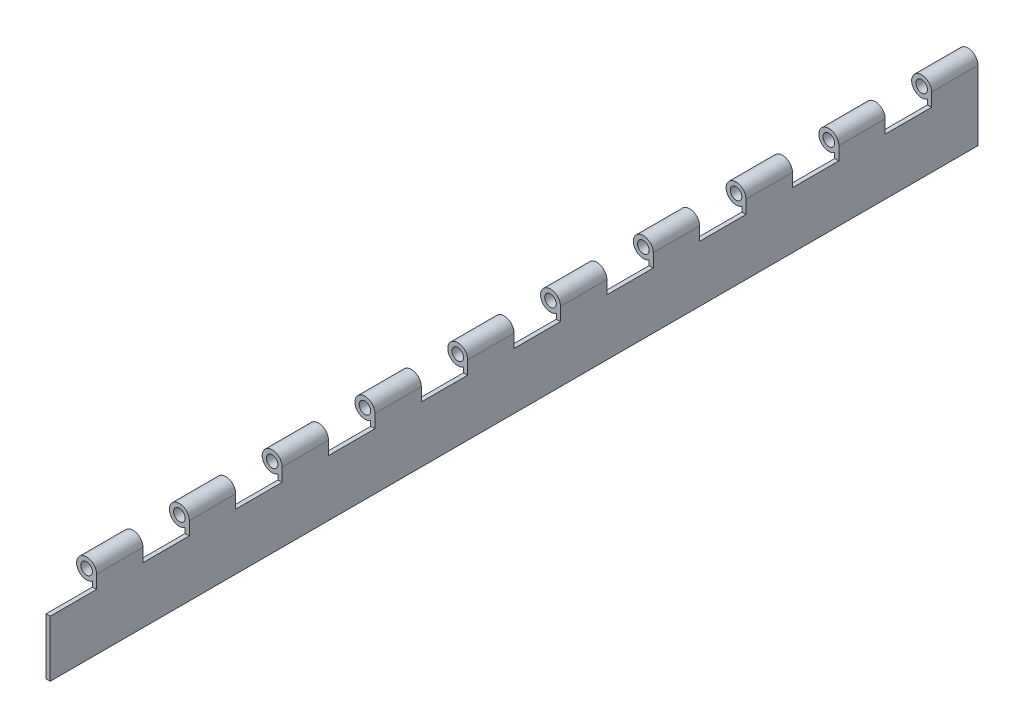
from build123d import *

# Parameters (mm, degrees)
SKETCH1_R           = 3.175
BOSS_EXTRUDE1_DEPTH = 508
SKETCH2_W           = 25.4
SKETCH2_H           = 12.7
CUT_EXTRUDE1_DEPTH  = 11.922
LPATTERN1_COUNT     = 10
LPATTERN1_PITCH     = 50.8


with BuildPart() as part:
    # Sketch1 → Boss-Extrude1 (new body)
    with BuildSketch(Plane.XY):
        with BuildLine():
            Line((5.461, 0), (5.461, -38.1))
            Line((5.461, -38.1), (3.175, -38.1))
            Line((3.175, -38.1), (3.175, -4.443185344))
            ThreePointArc((3.175, -4.443185344), (-4.855985791, 2.498384078), (5.461, 0))
        make_face()
        Circle(SKETCH1_R, mode=Mode.SUBTRACT)
    extrude(amount=BOSS_EXTRUDE1_DEPTH)

    # Sketch2 → Cut-Extrude1 (cut, through all)
    with BuildSketch(Plane(origin=(5.461, 0, 0), x_dir=(0, 0, -1), z_dir=(1, 0, 0))):
        with Locations((-495.3, -0.889)):
            Rectangle(SKETCH2_W, SKETCH2_H)
    cut_extrude1 = extrude(amount=-CUT_EXTRUDE1_DEPTH, mode=Mode.SUBTRACT)

    # LPattern1: Cut-Extrude1 ×10
    with Locations(*[(0, 0, -i * LPATTERN1_PITCH) for i in range(1, LPATTERN1_COUNT)]):
        add(cut_extrude1, mode=Mode.SUBTRACT)


solid = part.part
